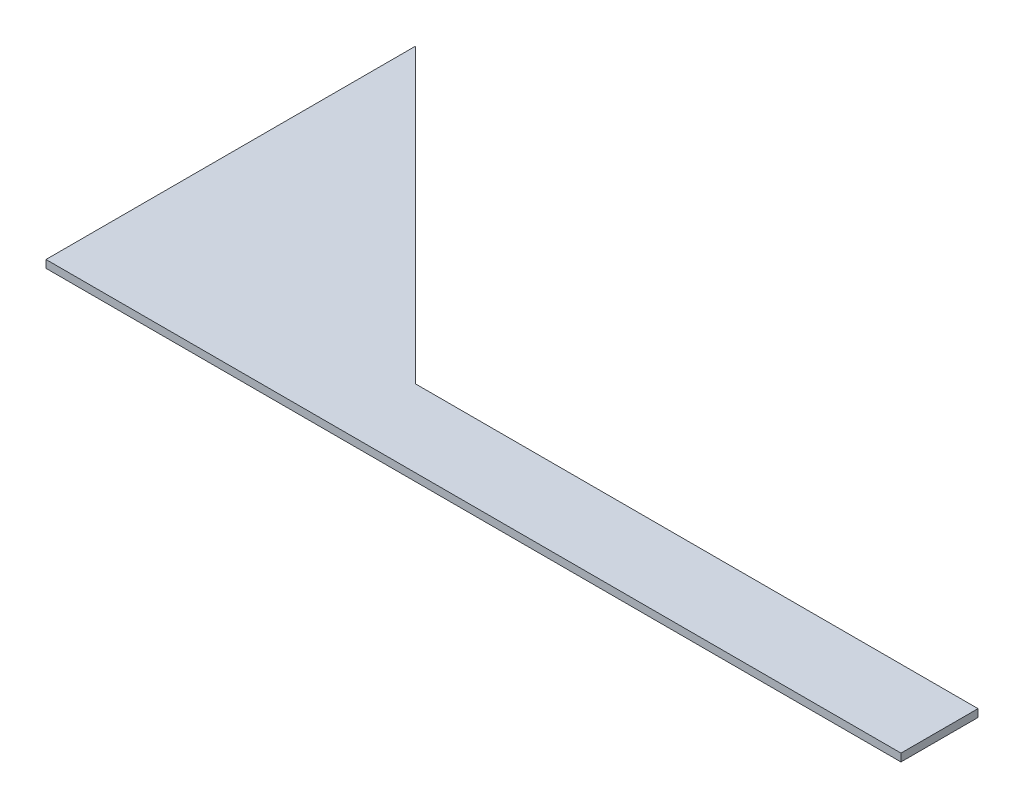
from build123d import *

# Parameters (mm, degrees)
BOSS_EXTRUDE1_DEPTH = 3.175


with BuildPart() as part:
    # Sketch1 → Boss-Extrude1 (new body)
    with BuildSketch(Plane(origin=(0, 0, 0), x_dir=(1, 0, 0), z_dir=(0, 1, 0))):
        Polygon((152.4, 0), (0, 0), (0, 152.4), align=None)
        Polygon((120.65, 31.75), (152.4, 0), (352.425, 0), (352.425, 31.75), align=None)
    extrude(amount=BOSS_EXTRUDE1_DEPTH)


solid = part.part
